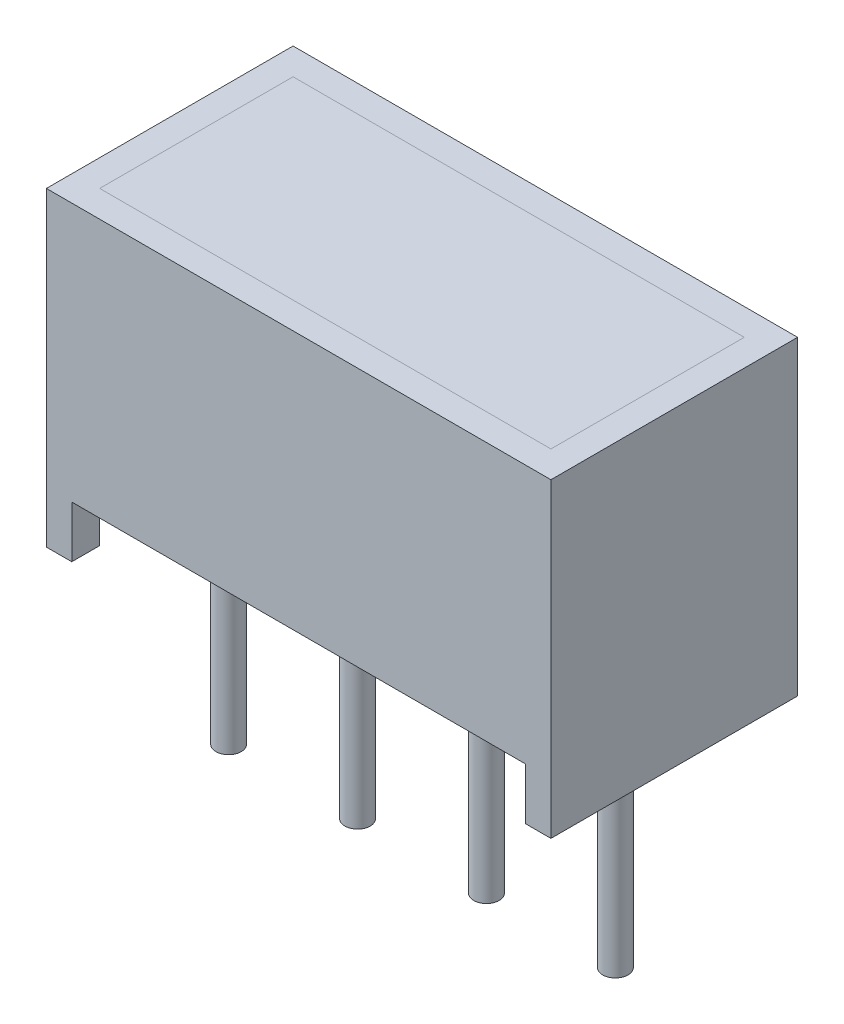
from build123d import *

# Parameters (mm, degrees)
SKETCH1_W          = 4.86
SKETCH1_H          = 6.12
EXTRUDE1_DEPTH     = 4.97
SKETCH3_W          = 8.94
SKETCH3_H          = 1.02
CUT_EXTRUDE1_DEPTH = 5.86
SKETCH2_W          = 8.89
SKETCH2_H          = 3.81
CUT_EXTRUDE2_DEPTH = 3.06
SKETCH4_R          = 0.25
EXTRUDE2_DEPTH     = 1.02
SKETCH4_3_R        = 0.25
EXTRUDE3_DEPTH     = 4
SKETCH2_3_W        = 8.89
SKETCH2_3_H        = 3.81
EXTRUDE4_DEPTH     = 3.06
SKETCH5_W          = 0.5
SKETCH5_H          = 1.02
CUT_EXTRUDE3_DEPTH = 0.5
SKETCH6_W          = 0.025316455
SKETCH6_H          = 0.026582278
SKETCH6_W_2        = 0.025316456
CUT_EXTRUDE4_DEPTH = 0.01


with BuildPart() as part:
    # Sketch1 → Extrude1 (new body, symmetric)
    with BuildSketch(Plane(origin=(0, 0, 0), x_dir=(0, 0, -1), z_dir=(1, 0, 0))):
        Rectangle(SKETCH1_W, SKETCH1_H)
    extrude(amount=EXTRUDE1_DEPTH, both=True)

    # Sketch3 → Cut-Extrude1 (cut, through all)
    with BuildSketch(Plane.XY.offset(2.43)):
        with Locations((0, -2.55)):
            Rectangle(SKETCH3_W, SKETCH3_H)
    extrude(amount=-CUT_EXTRUDE1_DEPTH, mode=Mode.SUBTRACT)

    # Sketch2 → Cut-Extrude2 (cut)
    with BuildSketch(Plane(origin=(0, 3.06, 0), x_dir=(-1, 0, 0), z_dir=(0, 1, 0))):
        Rectangle(SKETCH2_W, SKETCH2_H)
    extrude(amount=-CUT_EXTRUDE2_DEPTH, mode=Mode.SUBTRACT)

    # Sketch4 → Extrude2 (add)
    with BuildSketch(Plane.XZ.offset(3.06)):
        with Locations((-3.81, 0)):
            Circle(SKETCH4_R)
        with Locations((-1.27, 0)):
            Circle(SKETCH4_R)
        with Locations((1.27, 0)):
            Circle(SKETCH4_R)
        with Locations((3.81, 0)):
            Circle(SKETCH4_R)
    extrude(amount=-EXTRUDE2_DEPTH)

    # Sketch4_3 → Extrude3 (add)
    with BuildSketch(Plane.XZ.offset(3.06)):
        with Locations((-3.81, 0)):
            Circle(SKETCH4_3_R)
        with Locations((-1.27, 0)):
            Circle(SKETCH4_3_R)
        with Locations((1.27, 0)):
            Circle(SKETCH4_3_R)
        with Locations((3.81, 0)):
            Circle(SKETCH4_3_R)
    extrude(amount=EXTRUDE3_DEPTH)

    # Sketch5 → Cut-Extrude3 (cut)
    with BuildSketch(Plane.ZY.offset(4.97)):
        with Locations((1.63, -2.55)):
            Rectangle(SKETCH5_W, SKETCH5_H)
    extrude(amount=-CUT_EXTRUDE3_DEPTH, mode=Mode.SUBTRACT)

    # Sketch6 → Cut-Extrude4 (cut)
    with BuildSketch(Plane.XZ.offset(2.04)):
        Polygon((-0.559679779, -1.979541267), (-0.583137058, -2.054224811), (-0.607879937, -2.054224811), (-0.624296077, -2.003888577), (-0.639822184, -2.054224811), (-0.665553988, -2.054224811), (-0.688793703, -1.979541267), (-0.663615697, -1.979541267), (-0.650621235, -2.031024653), (-0.634205096, -1.979541267), (-0.612705887, -1.979541267), (-0.59638864, -2.031024653), (-0.583572184, -1.979541267), align=None)
        Polygon((-0.425502564, -1.979541267), (-0.448959842, -2.054224811), (-0.473702722, -2.054224811), (-0.490118861, -2.003888577), (-0.505644969, -2.054224811), (-0.531376773, -2.054224811), (-0.554616488, -1.979541267), (-0.529438482, -1.979541267), (-0.51644402, -2.031024653), (-0.50002788, -1.979541267), (-0.478528672, -1.979541267), (-0.462211425, -2.031024653), (-0.449394969, -1.979541267), align=None)
        Polygon((-0.291325349, -1.979541267), (-0.314782627, -2.054224811), (-0.339525507, -2.054224811), (-0.355941646, -2.003888577), (-0.371467754, -2.054224811), (-0.397199558, -2.054224811), (-0.420439273, -1.979541267), (-0.395261266, -1.979541267), (-0.382266804, -2.031024653), (-0.365850665, -1.979541267), (-0.344351456, -1.979541267), (-0.32803421, -2.031024653), (-0.315217754, -1.979541267), align=None)
        with Locations((-0.263477248, -2.040933672)):
            Rectangle(SKETCH6_W, SKETCH6_H)
        with BuildLine():
            add(Edge.make_bspline(
                [(-0.147021551, -2.023053925), (-0.14705804, -2.024276067), (-0.147129693, -2.026675945), (-0.14773941, -2.030183523), (-0.148732896, -2.033508228), (-0.150107014, -2.036670889), (-0.151895817, -2.039649507), (-0.154105407, -2.042429784), (-0.15666982, -2.045064584), (-0.15963603, -2.047470715), (-0.162916139, -2.049675091), (-0.166513715, -2.05157209), (-0.170392419, -2.053168573), (-0.174541005, -2.054507125), (-0.178987445, -2.055495705), (-0.183704974, -2.056219651), (-0.188698393, -2.05669298), (-0.192121971, -2.056734947), (-0.193876773, -2.056756457)],
                knots=[0, 0, 0, 0, 0.907352243, 1.781736951, 2.63548328, 3.47985091, 4.336556021, 5.208523475, 6.112432747, 7.062451073, 8.040435374, 9.043840564, 10.077958095, 11.152835584, 12.277940427, 13.457536469, 14.696825396, 16, 16, 16, 16], degree=3))
            add(Edge.make_bspline(
                [(-0.193876773, -2.056756457), (-0.195895028, -2.056732385), (-0.19980421, -2.056685761), (-0.205467735, -2.056257161), (-0.210735773, -2.055611022), (-0.215631488, -2.05464448), (-0.220236087, -2.053443715), (-0.224669354, -2.052152424), (-0.228950666, -2.050688008), (-0.231723756, -2.04958785), (-0.233097501, -2.049042849)],
                knots=[0, 0, 0, 0, 1.203215828, 2.33052265, 3.384689099, 4.366106119, 5.303329643, 6.221311756, 7.118865988, 8, 8, 8, 8], degree=3))
            Line((-0.233097501, -2.049042849), (-0.233097501, -2.025110887))
            Line((-0.233097501, -2.025110887), (-0.230249399, -2.025110887))
            add(Edge.make_bspline(
                [(-0.230249399, -2.025110887), (-0.228884085, -2.026192342), (-0.226161473, -2.028348903), (-0.22172824, -2.031111508), (-0.217080594, -2.033513671), (-0.212235123, -2.035487673), (-0.207338278, -2.037073997), (-0.202462901, -2.038167525), (-0.197697313, -2.038914874), (-0.194538744, -2.03899538), (-0.192986741, -2.039034938)],
                knots=[0, 0, 0, 0, 1.030622468, 2.055194264, 3.087043286, 4.125157485, 5.149848264, 6.130935704, 7.081611712, 8, 8, 8, 8], degree=3))
            add(Edge.make_bspline(
                [(-0.192986741, -2.039034938), (-0.192557965, -2.039034014), (-0.191639988, -2.039032037), (-0.190178462, -2.03890431), (-0.188526651, -2.038808733), (-0.186754142, -2.038601549), (-0.184957415, -2.038379688), (-0.183295014, -2.038004763), (-0.181785419, -2.037639896), (-0.180878898, -2.037271899), (-0.180447184, -2.037096647)],
                knots=[0, 0, 0, 0, 0.806402781, 1.726445712, 2.758724871, 3.919014682, 5.083870887, 6.16165551, 7.124521387, 8, 8, 8, 8], degree=3))
            add(Edge.make_bspline(
                [(-0.180447184, -2.037096647), (-0.179967621, -2.036868505), (-0.179025178, -2.036420158), (-0.177731579, -2.035609839), (-0.176563899, -2.034726374), (-0.175506527, -2.033761443), (-0.174632246, -2.032595693), (-0.174008379, -2.031187021), (-0.173663487, -2.029538003), (-0.173624463, -2.0283628), (-0.17360383, -2.027741425)],
                knots=[0, 0, 0, 0, 1.024747072, 2.013846092, 2.940605744, 3.850156746, 4.769278501, 5.73222711, 6.800942666, 8, 8, 8, 8], degree=3))
            add(Edge.make_bspline(
                [(-0.17360383, -2.027741425), (-0.173635674, -2.027195788), (-0.17369829, -2.026122904), (-0.174275483, -2.02458779), (-0.175184922, -2.023178621), (-0.176466512, -2.021909847), (-0.178059687, -2.020760313), (-0.180002071, -2.019778008), (-0.182252192, -2.01890482), (-0.183896263, -2.018486842), (-0.184758893, -2.018267533)],
                knots=[0, 0, 0, 0, 0.82557554, 1.623324704, 2.456147571, 3.35491006, 4.343819762, 5.427079081, 6.650009487, 8, 8, 8, 8], degree=3))
            add(Edge.make_bspline(
                [(-0.184758893, -2.018267533), (-0.186727519, -2.017819292), (-0.190766529, -2.016899642), (-0.196916354, -2.015760888), (-0.203044705, -2.014486028), (-0.206997471, -2.013279385), (-0.208928197, -2.012690001)],
                knots=[0, 0, 0, 0, 0.976100998, 2.002656142, 3.024398856, 4, 4, 4, 4], degree=3))
            add(Edge.make_bspline(
                [(-0.208928197, -2.012690001), (-0.209966715, -2.012337011), (-0.211988288, -2.011649883), (-0.214879799, -2.010488223), (-0.217541027, -2.009218394), (-0.21998074, -2.007862839), (-0.222181429, -2.006390299), (-0.224175697, -2.004848921), (-0.225938813, -2.003208881), (-0.227485618, -2.001469115), (-0.228810521, -1.999618412), (-0.229962906, -1.997673215), (-0.230945526, -1.995617795), (-0.231723564, -1.993447572), (-0.232348203, -1.991173917), (-0.232767185, -1.988796205), (-0.233066203, -1.986313076), (-0.233086926, -1.984618691), (-0.233097501, -1.983754084)],
                knots=[0, 0, 0, 0, 1.287047841, 2.5053592, 3.654260482, 4.74538952, 5.777514103, 6.75871007, 7.700244599, 8.599107454, 9.48590269, 10.366941872, 11.24940663, 12.154970331, 13.068988358, 14.012872203, 14.986013017, 16, 16, 16, 16], degree=3))
            add(Edge.make_bspline(
                [(-0.233097501, -1.983754084), (-0.233060199, -1.982597939), (-0.232986789, -1.980322667), (-0.232385361, -1.976993622), (-0.231358771, -1.973844886), (-0.229972707, -1.970841423), (-0.228144079, -1.968028337), (-0.225959285, -1.965349789), (-0.223335237, -1.962878198), (-0.220358116, -1.960577864), (-0.217070731, -1.958498465), (-0.213531748, -1.956667909), (-0.209762459, -1.955131258), (-0.205776912, -1.953857364), (-0.201558443, -1.952902693), (-0.19712121, -1.952183761), (-0.192447422, -1.951770579), (-0.189256, -1.951719329), (-0.187626773, -1.951693166)],
                knots=[0, 0, 0, 0, 0.894990994, 1.761326291, 2.609044902, 3.454222546, 4.315366365, 5.200560057, 6.125081389, 7.100429509, 8.110379559, 9.133447974, 10.182136699, 11.259192205, 12.370181258, 13.528580438, 14.738335141, 16, 16, 16, 16], degree=3))
            add(Edge.make_bspline(
                [(-0.187626773, -1.951693166), (-0.185958079, -1.951715319), (-0.18262352, -1.951759586), (-0.177642181, -1.952138144), (-0.172687752, -1.952690455), (-0.167825328, -1.953539696), (-0.163133165, -1.954507928), (-0.158714051, -1.955607201), (-0.154634498, -1.956844707), (-0.152060845, -1.957799109), (-0.15081902, -1.958259621)],
                knots=[0, 0, 0, 0, 1.065407564, 2.129008667, 3.188544425, 4.247469455, 5.279542408, 6.247502114, 7.154394069, 8, 8, 8, 8], degree=3))
            Line((-0.15081902, -1.958259621), (-0.15081902, -1.98080709))
            Line((-0.15081902, -1.98080709), (-0.153647342, -1.98080709))
            add(Edge.make_bspline(
                [(-0.153647342, -1.98080709), (-0.154720846, -1.980007802), (-0.156911624, -1.978376637), (-0.160561227, -1.976274901), (-0.164528847, -1.97433481), (-0.168810474, -1.972643153), (-0.173270255, -1.971185146), (-0.177853013, -1.970165587), (-0.182479229, -1.96952388), (-0.185580933, -1.969451091), (-0.187132311, -1.969414685)],
                knots=[0, 0, 0, 0, 0.892265782, 1.820912499, 2.804518821, 3.836954028, 4.889985052, 5.931488012, 6.965393252, 8, 8, 8, 8], degree=3))
            add(Edge.make_bspline(
                [(-0.187132311, -1.969414685), (-0.188227916, -1.969436587), (-0.190425559, -1.969480521), (-0.193694751, -1.969865407), (-0.196935229, -1.97050426), (-0.198969911, -1.971320311), (-0.199988323, -1.971728767)],
                knots=[0, 0, 0, 0, 0.999122297, 2.004111588, 3.001004448, 4, 4, 4, 4], degree=3))
            add(Edge.make_bspline(
                [(-0.199988323, -1.971728767), (-0.200422053, -1.971929946), (-0.201289223, -1.97233217), (-0.202496765, -1.973111795), (-0.203617737, -1.974028139), (-0.204613319, -1.975080896), (-0.205457753, -1.97624925), (-0.20607678, -1.977516832), (-0.206451272, -1.978880714), (-0.206493619, -1.979815813), (-0.206515222, -1.980292849)],
                knots=[0, 0, 0, 0, 1.004925302, 2.009180302, 3.014392739, 4.04465309, 5.049195417, 6.035570224, 6.99785458, 8, 8, 8, 8], degree=3))
            add(Edge.make_bspline(
                [(-0.206515222, -1.980292849), (-0.206480784, -1.980931015), (-0.206414976, -1.98215049), (-0.205808391, -1.983866286), (-0.204823558, -1.98534472), (-0.203662953, -1.98633964), (-0.202545824, -1.987037078), (-0.201510164, -1.987547589), (-0.200300937, -1.988030948), (-0.198929689, -1.988528416), (-0.197393362, -1.989019603), (-0.195684805, -1.98949515), (-0.193802088, -1.989944446), (-0.192486214, -1.990230637), (-0.191800032, -1.990379875)],
                knots=[0, 0, 0, 0, 1.173816843, 2.243057204, 3.312297565, 4.415174738, 5.03266065, 5.73970059, 6.541434878, 7.433956553, 8.430083051, 9.515931566, 10.70464786, 12, 12, 12, 12], degree=3))
            add(Edge.make_bspline(
                [(-0.191800032, -1.990379875), (-0.18996711, -1.990755319), (-0.186372144, -1.99149169), (-0.180972919, -1.992604056), (-0.175467931, -1.993869415), (-0.17179678, -1.995021411), (-0.169885475, -1.995621172)],
                knots=[0, 0, 0, 0, 0.995749986, 1.952994291, 2.934271555, 4, 4, 4, 4], degree=3))
            add(Edge.make_bspline(
                [(-0.169885475, -1.995621172), (-0.168938987, -1.995940531), (-0.167087503, -1.996565249), (-0.164445956, -1.997649933), (-0.161996903, -1.998832022), (-0.159718632, -2.000054508), (-0.157656551, -2.001417725), (-0.155763327, -2.002832372), (-0.154080308, -2.004360481), (-0.152582359, -2.005973339), (-0.151263958, -2.007683771), (-0.150128994, -2.009521874), (-0.149165848, -2.011476403), (-0.148357717, -2.013549474), (-0.1477797, -2.015756543), (-0.147345642, -2.018082843), (-0.14705482, -2.020528158), (-0.147032765, -2.022202605), (-0.147021551, -2.023053925)],
                knots=[0, 0, 0, 0, 1.237386967, 2.420528625, 3.534815053, 4.605870898, 5.620827102, 6.594482803, 7.531295079, 8.432978826, 9.318460435, 10.202471551, 11.10474705, 12.014900263, 12.954095338, 13.926516828, 14.945802342, 16, 16, 16, 16], degree=3))
        make_face()
        with BuildLine():
            Line((-0.054616488, -2.054224811), (-0.078667121, -2.054224811))
            Line((-0.078667121, -2.054224811), (-0.078667121, -2.046392533))
            add(Edge.make_bspline(
                [(-0.078667121, -2.046392533), (-0.079760376, -2.0472012), (-0.081868156, -2.048760299), (-0.085041896, -2.050839063), (-0.088070617, -2.052622225), (-0.090992218, -2.054164378), (-0.094007573, -2.055355225), (-0.097235076, -2.056177081), (-0.10073734, -2.056678201), (-0.103164314, -2.056729792), (-0.104418703, -2.056756457)],
                knots=[0, 0, 0, 0, 1.150906677, 2.218931226, 3.20955724, 4.125565256, 5.012676028, 5.946647191, 6.938718366, 8, 8, 8, 8], degree=3))
            add(Edge.make_bspline(
                [(-0.104418703, -2.056756457), (-0.105435048, -2.056733728), (-0.107414166, -2.056689468), (-0.110291496, -2.05634473), (-0.112998808, -2.055806584), (-0.115514957, -2.055000728), (-0.117880303, -2.054026611), (-0.120031821, -2.052767524), (-0.12201951, -2.051308187), (-0.123822888, -2.049631251), (-0.125413507, -2.047710289), (-0.126800558, -2.045587538), (-0.12797637, -2.0432529), (-0.128918008, -2.040701533), (-0.129672941, -2.037943089), (-0.130196919, -2.034963882), (-0.130517498, -2.031776743), (-0.130549439, -2.029581614), (-0.130565855, -2.028453451)],
                knots=[0, 0, 0, 0, 1.108935798, 2.159418225, 3.158520219, 4.116592843, 5.038730546, 5.944611115, 6.829677354, 7.725673622, 8.624842385, 9.544872214, 10.487719724, 11.471363217, 12.50822837, 13.604887271, 14.769056852, 16, 16, 16, 16], degree=3))
            Line((-0.130565855, -2.028453451), (-0.130565855, -1.979541267))
            Line((-0.130565855, -1.979541267), (-0.106515222, -1.979541267))
            Line((-0.106515222, -1.979541267), (-0.106515222, -2.017120381))
            add(Edge.make_bspline(
                [(-0.106515222, -2.017120381), (-0.106513587, -2.018036852), (-0.106510456, -2.019791068), (-0.106428117, -2.022296874), (-0.106307217, -2.024565047), (-0.106168512, -2.026607075), (-0.105915495, -2.028453826), (-0.105537787, -2.030119987), (-0.105066961, -2.031639589), (-0.104602642, -2.032546291), (-0.104379146, -2.032982723)],
                knots=[0, 0, 0, 0, 1.361401701, 2.605856924, 3.723918663, 4.735739235, 5.645738665, 6.489217889, 7.27279937, 8, 8, 8, 8], degree=3))
            add(Edge.make_bspline(
                [(-0.104379146, -2.032982723), (-0.104149106, -2.033381371), (-0.103696868, -2.034165078), (-0.102777057, -2.035172226), (-0.101701074, -2.036009132), (-0.100431435, -2.036681776), (-0.098938354, -2.037165479), (-0.097206354, -2.037512227), (-0.095220338, -2.03772605), (-0.093811419, -2.037754212), (-0.093065855, -2.037769115)],
                knots=[0, 0, 0, 0, 0.849057291, 1.669173542, 2.503217716, 3.359509317, 4.311793648, 5.394940091, 6.621469141, 8, 8, 8, 8], degree=3))
            add(Edge.make_bspline(
                [(-0.093065855, -2.037769115), (-0.09252459, -2.037751658), (-0.091411713, -2.037715764), (-0.089706501, -2.037485836), (-0.087917472, -2.037124179), (-0.085403275, -2.036465156), (-0.08222713, -2.035285978), (-0.079862991, -2.033927176), (-0.078667121, -2.033239843)],
                knots=[0, 0, 0, 0, 0.638164724, 1.312110757, 2.025558264, 2.789159289, 4.375836335, 6, 6, 6, 6], degree=3))
            Line((-0.078667121, -2.033239843), (-0.078667121, -1.979541267))
            Line((-0.078667121, -1.979541267), (-0.054616488, -1.979541267))
            Line((-0.054616488, -1.979541267), (-0.054616488, -2.054224811))
        make_face()
        with BuildLine():
            Line((0.042851866, -2.054224811), (0.018801234, -2.054224811))
            Line((0.018801234, -2.054224811), (0.018801234, -2.016645697))
            add(Edge.make_bspline(
                [(0.018801234, -2.016645697), (0.018780909, -2.015115224), (0.018740374, -2.012062812), (0.018406794, -2.008306036), (0.018073085, -2.005458246), (0.017696262, -2.003622179), (0.017266076, -2.002073843), (0.01685363, -2.001188105), (0.016665158, -2.000783356)],
                knots=[0, 0, 0, 0, 1.709235885, 3.408940626, 4.211008593, 4.910095588, 5.501954032, 6, 6, 6, 6], degree=3))
            add(Edge.make_bspline(
                [(0.016665158, -2.000783356), (0.016420729, -2.000385233), (0.015941493, -1.999604658), (0.015003677, -1.998592636), (0.013907028, -1.997756422), (0.012628305, -1.997091473), (0.011143651, -1.996605574), (0.009430977, -1.996218915), (0.007445007, -1.996050355), (0.006037638, -1.996015446), (0.005292531, -1.995996963)],
                knots=[0, 0, 0, 0, 0.860145871, 1.686437142, 2.528070002, 3.393017362, 4.331453407, 5.402595683, 6.624848233, 8, 8, 8, 8], degree=3))
            add(Edge.make_bspline(
                [(0.005292531, -1.995996963), (0.004160641, -1.996053544), (0.001849408, -1.996169077), (-0.001011883, -1.996882668), (-0.003338759, -1.997694965), (-0.005184379, -1.998469202), (-0.007100908, -1.999423828), (-0.008384333, -2.000150902), (-0.009046868, -2.000526235)],
                knots=[0, 0, 0, 0, 1.338419466, 2.732951426, 3.468143565, 4.254837763, 5.099104234, 6, 6, 6, 6], degree=3))
            Line((-0.009046868, -2.000526235), (-0.009046868, -2.054224811))
            Line((-0.009046868, -2.054224811), (-0.033097501, -2.054224811))
            Line((-0.033097501, -2.054224811), (-0.033097501, -1.979541267))
            Line((-0.033097501, -1.979541267), (-0.009046868, -1.979541267))
            Line((-0.009046868, -1.979541267), (-0.009046868, -1.987373546))
            add(Edge.make_bspline(
                [(-0.009046868, -1.987373546), (-0.00798963, -1.986567108), (-0.005931655, -1.984997329), (-0.002754902, -1.982963919), (0.000315809, -1.981154063), (0.003370331, -1.979641928), (0.006494829, -1.978443328), (0.00976246, -1.977627725), (0.013179172, -1.977084777), (0.015515845, -1.977034965), (0.016704715, -1.977009621)],
                knots=[0, 0, 0, 0, 1.126064518, 2.191951536, 3.19307265, 4.144813015, 5.076393104, 6.021983703, 6.993610568, 8, 8, 8, 8], degree=3))
            add(Edge.make_bspline(
                [(0.016704715, -1.977009621), (0.017700986, -1.977035011), (0.019645885, -1.977084574), (0.022480646, -1.977394284), (0.025152066, -1.977944948), (0.027644341, -1.978742778), (0.029986958, -1.979728391), (0.032148914, -1.980959901), (0.03414094, -1.982418341), (0.035969509, -1.984079282), (0.03759969, -1.98596924), (0.039019176, -1.988085613), (0.0401906, -1.990434342), (0.041199432, -1.992981478), (0.041933657, -1.995759249), (0.042460108, -1.998750015), (0.042810538, -2.001955197), (0.042837815, -2.004171097), (0.042851866, -2.005312628)],
                knots=[0, 0, 0, 0, 1.088441561, 2.124831547, 3.110816719, 4.062969431, 4.979391633, 5.88258537, 6.774334107, 7.671621258, 8.575503974, 9.49441354, 10.447872957, 11.437639084, 12.482478955, 13.580222388, 14.753440527, 16, 16, 16, 16], degree=3))
            Line((0.042851866, -2.005312628), (0.042851866, -2.054224811))
        make_face()
        Polygon((0.137788575, -2.054224811), (0.065636677, -2.054224811), (0.065636677, -1.954224811), (0.090953132, -1.954224811), (0.090953132, -2.03523747), (0.137788575, -2.03523747), align=None)
        Polygon((0.225130347, -2.054224811), (0.152978449, -2.054224811), (0.152978449, -1.954224811), (0.225130347, -1.954224811), (0.225130347, -1.973212153), (0.178294904, -1.973212153), (0.178294904, -1.990933672), (0.221332879, -1.990933672), (0.221332879, -2.009921014), (0.178294904, -2.009921014), (0.178294904, -2.03523747), (0.225130347, -2.03523747), align=None)
        with BuildLine():
            add(Edge.make_bspline(
                [(0.341586044, -2.004323704), (0.341566728, -2.005471393), (0.341528476, -2.007744279), (0.341233285, -2.011109085), (0.340707259, -2.014374761), (0.340028078, -2.017559009), (0.339105572, -2.020637937), (0.338023859, -2.023645514), (0.336714213, -2.026551008), (0.33520936, -2.029352442), (0.333559888, -2.032024545), (0.331785139, -2.034544754), (0.32993936, -2.036927972), (0.327950047, -2.039122866), (0.325870865, -2.041164885), (0.323695337, -2.043055699), (0.321390272, -2.04475913), (0.31978311, -2.045782014), (0.31897924, -2.04629364)],
                knots=[0, 0, 0, 0, 1.105570398, 2.18947457, 3.250358341, 4.290584537, 5.323553275, 6.344225964, 7.367641686, 8.3905646, 9.405808457, 10.390761353, 11.358902336, 12.307789878, 13.241960776, 14.165076779, 15.082208636, 16, 16, 16, 16], degree=3))
            add(Edge.make_bspline(
                [(0.31897924, -2.04629364), (0.317740019, -2.04700581), (0.315255254, -2.048433784), (0.311271308, -2.050101915), (0.307140189, -2.051509871), (0.302781635, -2.052558061), (0.298135286, -2.053286794), (0.293140629, -2.053849844), (0.287739502, -2.054150209), (0.284004619, -2.054199377), (0.282072594, -2.054224811)],
                knots=[0, 0, 0, 0, 0.896298978, 1.797171328, 2.70531317, 3.633678302, 4.606491125, 5.655688921, 6.787306437, 8, 8, 8, 8], degree=3))
            Line((0.282072594, -2.054224811), (0.246649335, -2.054224811))
            Line((0.246649335, -2.054224811), (0.246649335, -1.954224811))
            Line((0.246649335, -1.954224811), (0.283081297, -1.954224811))
            add(Edge.make_bspline(
                [(0.283081297, -1.954224811), (0.285060021, -1.954241507), (0.288876734, -1.95427371), (0.294387152, -1.954689678), (0.299485531, -1.955289198), (0.30417011, -1.95621589), (0.308478516, -1.957324541), (0.312409539, -1.958687577), (0.316021428, -1.960185849), (0.318200255, -1.961459596), (0.319256139, -1.962076868)],
                knots=[0, 0, 0, 0, 1.267192274, 2.444256634, 3.537982003, 4.553396635, 5.500903572, 6.385021601, 7.217363933, 8, 8, 8, 8], degree=3))
            add(Edge.make_bspline(
                [(0.319256139, -1.962076868), (0.320107092, -1.962613409), (0.321799217, -1.963680322), (0.324200431, -1.965462175), (0.326429858, -1.967418252), (0.328558362, -1.96947007), (0.330538176, -1.971672958), (0.332381389, -1.974011662), (0.334085156, -1.976489769), (0.335643311, -1.979099188), (0.337063396, -1.981829428), (0.338255476, -1.984701773), (0.339294838, -1.987684647), (0.34014092, -1.990783586), (0.34079725, -1.994000976), (0.341243334, -1.997338456), (0.341526767, -2.000791645), (0.341566118, -2.003136438), (0.341586044, -2.004323704)],
                knots=[0, 0, 0, 0, 0.964043478, 1.917004671, 2.862223898, 3.805158963, 4.749279098, 5.698713747, 6.657523689, 7.629652222, 8.610369353, 9.604453025, 10.607693792, 11.636365947, 12.681120053, 13.752669011, 14.862083412, 16, 16, 16, 16], degree=3))
        make_face()
        with BuildLine():
            add(Edge.make_bspline(
                [(0.315003765, -2.004165476), (0.314993294, -2.003360763), (0.314972755, -2.001782271), (0.314784432, -1.999466095), (0.314513845, -1.997240046), (0.314124711, -1.995096413), (0.313584278, -1.993046265), (0.312952097, -1.991084696), (0.312225007, -1.989205772), (0.311344077, -1.987428113), (0.310370252, -1.985719776), (0.309222809, -1.984134248), (0.307974458, -1.982621365), (0.306596175, -1.98119338), (0.305053233, -1.979887484), (0.303393131, -1.978657408), (0.301592773, -1.977529082), (0.300319785, -1.976869032), (0.299675442, -1.976534938)],
                knots=[0, 0, 0, 0, 1.152052275, 2.259818351, 3.325348653, 4.362224493, 5.376551665, 6.358740615, 7.312387502, 8.258104984, 9.197203025, 10.124507262, 11.056413058, 12.004389423, 12.961766972, 13.947352551, 14.961020569, 16, 16, 16, 16], degree=3))
            add(Edge.make_bspline(
                [(0.299675442, -1.976534938), (0.299000545, -1.976228226), (0.297662851, -1.975620301), (0.295592028, -1.974889109), (0.293502644, -1.974316273), (0.291301045, -1.973885415), (0.288831285, -1.973563484), (0.285905703, -1.973366226), (0.282449794, -1.973224056), (0.279963079, -1.973216305), (0.278631139, -1.973212153)],
                knots=[0, 0, 0, 0, 0.826967603, 1.639107464, 2.447640171, 3.242670507, 4.14065217, 5.225198036, 6.513753944, 8, 8, 8, 8], degree=3))
            Line((0.278631139, -1.973212153), (0.27196579, -1.973212153))
            Line((0.27196579, -1.973212153), (0.27196579, -2.03523747))
            Line((0.27196579, -2.03523747), (0.278631139, -2.03523747))
            add(Edge.make_bspline(
                [(0.278631139, -2.03523747), (0.279389346, -2.035232724), (0.280853112, -2.035223562), (0.28296935, -2.035180448), (0.284935166, -2.035133734), (0.286739971, -2.035016697), (0.288392315, -2.034946197), (0.289878462, -2.034762526), (0.291215412, -2.034628051), (0.292787893, -2.034350329), (0.294643079, -2.033944353), (0.296809869, -2.033261196), (0.298950568, -2.032411621), (0.300339118, -2.031726542), (0.301040158, -2.031380666)],
                knots=[0, 0, 0, 0, 1.186805873, 2.291202465, 3.313317863, 4.264127762, 5.122212376, 5.900577546, 6.607154111, 7.224697658, 8.398873738, 9.57716935, 10.776782771, 12, 12, 12, 12], degree=3))
            add(Edge.make_bspline(
                [(0.301040158, -2.031380666), (0.301625271, -2.031039148), (0.302779192, -2.03036563), (0.304402732, -2.02923158), (0.305910321, -2.02802377), (0.307306799, -2.026735629), (0.308568385, -2.025346244), (0.309724473, -2.023886778), (0.31072986, -2.022326457), (0.311969113, -2.02013763), (0.313216203, -2.017112873), (0.314248603, -2.013140119), (0.31488775, -2.008781207), (0.314964103, -2.005743467), (0.315003765, -2.004165476)],
                knots=[0, 0, 0, 0, 0.755237594, 1.489427721, 2.205882609, 2.908165467, 3.605466573, 4.296695275, 4.981837198, 5.673065901, 7.099889822, 8.61390339, 10.241051878, 12, 12, 12, 12], degree=3))
        make_face(mode=Mode.SUBTRACT)
        with Locations((0.373231613, -2.040933672)):
            Rectangle(SKETCH6_W_2, SKETCH6_H)
        with BuildLine():
            add(Edge.make_bspline(
                [(0.447875601, -2.056756457), (0.446285484, -2.056734654), (0.44316434, -2.056691857), (0.438593052, -2.056214829), (0.434227686, -2.055497533), (0.430082063, -2.054475214), (0.42617152, -2.053134695), (0.42251657, -2.051464688), (0.419099898, -2.049497493), (0.417037978, -2.047912596), (0.416012468, -2.047124337)],
                knots=[0, 0, 0, 0, 1.123701398, 2.205645569, 3.245398653, 4.249180969, 5.220497262, 6.163202923, 7.086456062, 8, 8, 8, 8], degree=3))
            add(Edge.make_bspline(
                [(0.416012468, -2.047124337), (0.415060833, -2.046269504), (0.413161243, -2.044563143), (0.410693616, -2.0415926), (0.40857554, -2.038303627), (0.406763285, -2.034711974), (0.405331333, -2.030792089), (0.404338798, -2.026542194), (0.403711194, -2.021984865), (0.403645243, -2.01883666), (0.40361136, -2.017219273)],
                knots=[0, 0, 0, 0, 0.916342154, 1.829140869, 2.758848968, 3.716597128, 4.708179637, 5.743612459, 6.840783343, 8, 8, 8, 8], degree=3))
            add(Edge.make_bspline(
                [(0.40361136, -2.017219273), (0.403650121, -2.015516046), (0.403725243, -2.012214966), (0.404389003, -2.007442779), (0.405458615, -2.003025098), (0.406996173, -1.99897319), (0.408926615, -1.995279998), (0.411191108, -1.991908164), (0.413811634, -1.988865239), (0.415818772, -1.9871198), (0.416823385, -1.986246172)],
                knots=[0, 0, 0, 0, 1.171797512, 2.271099083, 3.308930235, 4.294129479, 5.24602549, 6.17106565, 7.084581485, 8, 8, 8, 8], degree=3))
            add(Edge.make_bspline(
                [(0.416823385, -1.986246172), (0.41784917, -1.985477393), (0.419913127, -1.98393055), (0.423312667, -1.982035738), (0.42692488, -1.980431221), (0.430755996, -1.979185335), (0.434736515, -1.978236798), (0.438802055, -1.977509826), (0.442948422, -1.977089801), (0.445738608, -1.977036477), (0.447143797, -1.977009621)],
                knots=[0, 0, 0, 0, 0.952097844, 1.915695341, 2.885641886, 3.886921822, 4.905719434, 5.925883802, 6.95543633, 8, 8, 8, 8], degree=3))
            add(Edge.make_bspline(
                [(0.447143797, -1.977009621), (0.448390523, -1.977026585), (0.450842011, -1.977059941), (0.454442944, -1.977382599), (0.457891529, -1.977912763), (0.461188841, -1.978656357), (0.464361989, -1.979549156), (0.467421461, -1.980580437), (0.470386277, -1.981718378), (0.472286955, -1.982602593), (0.473231613, -1.983042058)],
                knots=[0, 0, 0, 0, 1.107671842, 2.178058178, 3.209662749, 4.206063564, 5.179815947, 6.137646632, 7.07438927, 8, 8, 8, 8], degree=3))
            Line((0.473231613, -1.983042058), (0.473231613, -2.0035919))
            Line((0.473231613, -2.0035919), (0.46988905, -2.0035919))
            add(Edge.make_bspline(
                [(0.46988905, -2.0035919), (0.469390281, -2.003173673), (0.468308346, -2.002266449), (0.466506994, -2.000865436), (0.464373483, -1.999314871), (0.462722275, -1.998428868), (0.461839208, -1.997955033)],
                knots=[0, 0, 0, 0, 0.792878214, 1.719922066, 2.780612869, 4, 4, 4, 4], degree=3))
            add(Edge.make_bspline(
                [(0.461839208, -1.997955033), (0.460911549, -1.997512164), (0.45900452, -1.996601741), (0.456444543, -1.995782198), (0.454255512, -1.995203661), (0.452443628, -1.994950851), (0.450510208, -1.994760503), (0.449174938, -1.994741108), (0.448488734, -1.99473114)],
                knots=[0, 0, 0, 0, 1.33256682, 2.739414054, 3.480190821, 4.267897792, 5.109861573, 6, 6, 6, 6], degree=3))
            add(Edge.make_bspline(
                [(0.448488734, -1.99473114), (0.447723185, -1.9947507), (0.446239587, -1.994788605), (0.444077985, -1.995065527), (0.442059909, -1.995544262), (0.440155501, -1.996182674), (0.438416754, -1.997078913), (0.436774224, -1.998091181), (0.435299749, -1.999345689), (0.433957802, -2.000763429), (0.432770318, -2.002353943), (0.431743565, -2.00408043), (0.430860839, -2.005938323), (0.430158946, -2.007936231), (0.429601436, -2.010066093), (0.42921187, -2.012328903), (0.428970092, -2.014728501), (0.428942149, -2.016374797), (0.428927816, -2.017219273)],
                knots=[0, 0, 0, 0, 1.087094245, 2.106738054, 3.087824582, 4.029427112, 4.95060567, 5.859714611, 6.763601524, 7.690850518, 8.627131371, 9.576106403, 10.539384251, 11.543302637, 12.578856349, 13.662518017, 14.800975475, 16, 16, 16, 16], degree=3))
            add(Edge.make_bspline(
                [(0.428927816, -2.017219273), (0.42894259, -2.01808343), (0.428971296, -2.019762442), (0.429204811, -2.022204053), (0.429620702, -2.024485485), (0.43019195, -2.026610804), (0.430916298, -2.028576823), (0.431821415, -2.030374219), (0.432857771, -2.032031027), (0.434102329, -2.033493639), (0.435466213, -2.03480996), (0.436981105, -2.035946095), (0.438640344, -2.036894239), (0.440422524, -2.037698703), (0.442355565, -2.038277101), (0.444412102, -2.038713793), (0.446601657, -2.039002349), (0.448112011, -2.039023912), (0.448884303, -2.039034938)],
                knots=[0, 0, 0, 0, 1.230336593, 2.390482092, 3.487897344, 4.52859895, 5.520747884, 6.465347575, 7.38981449, 8.296085817, 9.192433006, 10.084246191, 10.984321635, 11.908883871, 12.862027947, 13.850751296, 14.901019963, 16, 16, 16, 16], degree=3))
            add(Edge.make_bspline(
                [(0.448884303, -2.039034938), (0.449610146, -2.039026715), (0.451025148, -2.039010683), (0.45308357, -2.038794617), (0.455037487, -2.03851529), (0.456872034, -2.038074014), (0.458576283, -2.03753913), (0.460141936, -2.036968303), (0.461554543, -2.036364023), (0.462415878, -2.035896408), (0.462828132, -2.035672596)],
                knots=[0, 0, 0, 0, 1.200879421, 2.341068892, 3.423000803, 4.465923194, 5.460027553, 6.378409259, 7.223869634, 8, 8, 8, 8], degree=3))
            add(Edge.make_bspline(
                [(0.462828132, -2.035672596), (0.463536488, -2.03524491), (0.464897862, -2.034422951), (0.46672298, -2.033002491), (0.468367105, -2.031596051), (0.469391211, -2.030639284), (0.46988905, -2.030174178)],
                knots=[0, 0, 0, 0, 1.105932972, 2.12546697, 3.088749538, 4, 4, 4, 4], degree=3))
            Line((0.46988905, -2.030174178), (0.473231613, -2.030174178))
            Line((0.473231613, -2.030174178), (0.473231613, -2.050882248))
            add(Edge.make_bspline(
                [(0.473231613, -2.050882248), (0.472286237, -2.05131979), (0.470395256, -2.05219498), (0.467480478, -2.05334813), (0.464487236, -2.05432101), (0.461436006, -2.055213356), (0.458266374, -2.055911551), (0.454949025, -2.056400781), (0.45146772, -2.05670252), (0.449089304, -2.056738233), (0.447875601, -2.056756457)],
                knots=[0, 0, 0, 0, 0.952024047, 1.90427691, 2.862762905, 3.827874523, 4.80891974, 5.826446878, 6.890837857, 8, 8, 8, 8], degree=3))
        make_face()
        with BuildLine():
            add(Edge.make_bspline(
                [(0.565636677, -2.016922596), (0.565611757, -2.018427428), (0.565563181, -2.021360749), (0.565026973, -2.025633569), (0.564203511, -2.029664011), (0.563070186, -2.033464848), (0.561552333, -2.037007894), (0.559709918, -2.040303848), (0.557536328, -2.043356031), (0.555046009, -2.046146257), (0.552244523, -2.048644449), (0.549170758, -2.050840642), (0.545800891, -2.05264769), (0.542192145, -2.05417424), (0.538302838, -2.055330341), (0.534143744, -2.056148291), (0.529726234, -2.056682623), (0.526687869, -2.056731435), (0.525130347, -2.056756457)],
                knots=[0, 0, 0, 0, 1.120122129, 2.18341868, 3.201215738, 4.181270334, 5.131540819, 6.065757527, 6.988093576, 7.916512302, 8.844931028, 9.778115023, 10.722851943, 11.686686084, 12.691660064, 13.738321946, 14.84062285, 16, 16, 16, 16], degree=3))
            add(Edge.make_bspline(
                [(0.525130347, -2.056756457), (0.523572799, -2.056731517), (0.520534381, -2.056682865), (0.516117247, -2.056147395), (0.511963027, -2.055334678), (0.508078375, -2.054165443), (0.504464064, -2.052653352), (0.501090237, -2.050839911), (0.498016055, -2.048644658), (0.495214853, -2.046146147), (0.492723816, -2.043356262), (0.490552811, -2.040303032), (0.488701872, -2.03701324), (0.48722148, -2.033455965), (0.486048948, -2.029668757), (0.485236169, -2.025632759), (0.484696852, -2.021360968), (0.484648714, -2.018427502), (0.484624018, -2.016922596)],
                knots=[0, 0, 0, 0, 1.159424321, 2.261770074, 3.308474541, 4.308788811, 5.277191138, 6.221966496, 7.15518846, 8.08364496, 9.01210146, 9.934475036, 10.868729753, 11.817121636, 12.798654016, 13.816492484, 14.879832297, 16, 16, 16, 16], degree=3))
            add(Edge.make_bspline(
                [(0.484624018, -2.016922596), (0.484649141, -2.015411172), (0.484698226, -2.012458162), (0.485233596, -2.008159289), (0.486051613, -2.004098639), (0.487211646, -2.000290326), (0.488727919, -1.996738726), (0.490568943, -1.993436621), (0.492765411, -1.990390046), (0.49527491, -1.987600294), (0.498086704, -1.985103913), (0.501180635, -1.982931008), (0.504532555, -1.981094351), (0.508139754, -1.979572517), (0.512026309, -1.978437952), (0.516163252, -1.977620373), (0.520560646, -1.977082301), (0.523579384, -1.977034289), (0.525130347, -1.977009621)],
                knots=[0, 0, 0, 0, 1.124034801, 2.196132384, 3.217834281, 4.203147447, 5.152578239, 6.085969439, 7.010345409, 7.941219594, 8.872481455, 9.802010446, 10.748267785, 11.711250247, 12.709230373, 13.754967386, 14.846549946, 16, 16, 16, 16], degree=3))
            add(Edge.make_bspline(
                [(0.525130347, -1.977009621), (0.526701091, -1.977034334), (0.529759267, -1.977082447), (0.534202596, -1.977618786), (0.538376726, -1.978431312), (0.542274335, -1.979599382), (0.545898343, -1.981102652), (0.54924552, -1.982957598), (0.552330478, -1.985131948), (0.555098741, -1.987661777), (0.5575825, -1.990456731), (0.559744856, -1.993514411), (0.561580332, -1.996821987), (0.563056075, -2.000383862), (0.564230277, -2.004176494), (0.565050689, -2.008210921), (0.565556841, -2.012485827), (0.565609602, -2.01541797), (0.565636677, -2.016922596)],
                knots=[0, 0, 0, 0, 1.167473013, 2.273023816, 3.322954552, 4.326451713, 5.293391623, 6.234801871, 7.166614545, 8.093305908, 9.017100806, 9.942078766, 10.872536262, 11.824015763, 12.804065898, 13.820367293, 14.881523901, 16, 16, 16, 16], degree=3))
        make_face()
        with BuildLine():
            add(Edge.make_bspline(
                [(0.535929398, -2.035415476), (0.536284144, -2.034915283), (0.537006094, -2.033897331), (0.537882034, -2.032202139), (0.538641687, -2.030370871), (0.539260374, -2.028344588), (0.539770516, -2.026046811), (0.540072136, -2.023389879), (0.54030495, -2.020354993), (0.540314931, -2.018202185), (0.540320221, -2.017061046)],
                knots=[0, 0, 0, 0, 0.765094823, 1.557058493, 2.376706509, 3.238810155, 4.199844458, 5.312104478, 6.575226644, 8, 8, 8, 8], degree=3))
            add(Edge.make_bspline(
                [(0.540320221, -2.017061046), (0.540302532, -2.015986164), (0.540268642, -2.013926808), (0.540082272, -2.010967045), (0.539733597, -2.008283618), (0.539235719, -2.005866222), (0.538625949, -2.003695534), (0.537900014, -2.001753172), (0.537061496, -2.00003457), (0.536376029, -1.999029338), (0.536048069, -1.998548387)],
                knots=[0, 0, 0, 0, 1.337076348, 2.561692668, 3.686680134, 4.69989255, 5.629188848, 6.488203485, 7.276684665, 8, 8, 8, 8], degree=3))
            add(Edge.make_bspline(
                [(0.536048069, -1.998548387), (0.535709496, -1.99811055), (0.535048246, -1.997255433), (0.533890492, -1.996151799), (0.53261001, -1.995273849), (0.531229164, -1.994605184), (0.529788455, -1.994091675), (0.528282332, -1.993735634), (0.526725772, -1.993514471), (0.525665093, -1.993481793), (0.525130347, -1.993465318)],
                knots=[0, 0, 0, 0, 1.058499091, 2.067300666, 3.047512573, 4.018335651, 4.996351322, 5.969796037, 6.97646375, 8, 8, 8, 8], degree=3))
            add(Edge.make_bspline(
                [(0.525130347, -1.993465318), (0.524602445, -1.993476348), (0.523569886, -1.993497922), (0.522066808, -1.993676439), (0.520651155, -1.993976437), (0.51930599, -1.994380623), (0.518020842, -1.994991999), (0.516789565, -1.995840817), (0.515574178, -1.996917396), (0.51483585, -1.997767732), (0.514449968, -1.998212153)],
                knots=[0, 0, 0, 0, 1.04189444, 2.037910168, 2.982338511, 3.896140384, 4.804271323, 5.778885192, 6.839150358, 8, 8, 8, 8], degree=3))
            add(Edge.make_bspline(
                [(0.514449968, -1.998212153), (0.514114534, -1.998685821), (0.513410544, -1.999679929), (0.512561355, -2.001400298), (0.511792056, -2.003345789), (0.511112767, -2.005536925), (0.510581582, -2.008004465), (0.510223394, -2.010763078), (0.509978714, -2.013813013), (0.509953598, -2.015946319), (0.509940474, -2.017061046)],
                knots=[0, 0, 0, 0, 0.70629823, 1.482341141, 2.329662943, 3.254583898, 4.274063958, 5.401087491, 6.641978366, 8, 8, 8, 8], degree=3))
            add(Edge.make_bspline(
                [(0.509940474, -2.017061046), (0.509946414, -2.018063784), (0.50995792, -2.020005916), (0.510200115, -2.022808248), (0.510486942, -2.025416692), (0.510973512, -2.027804745), (0.51154535, -2.029989922), (0.512293393, -2.031941515), (0.513116733, -2.033696588), (0.513817088, -2.034724328), (0.51415329, -2.035217691)],
                knots=[0, 0, 0, 0, 1.270983191, 2.461674417, 3.564986371, 4.596265355, 5.549463796, 6.425202083, 7.244022889, 8, 8, 8, 8], degree=3))
            add(Edge.make_bspline(
                [(0.51415329, -2.035217691), (0.514493653, -2.035634466), (0.515164699, -2.036456164), (0.516312494, -2.037532304), (0.517580467, -2.038406862), (0.518930085, -2.039129851), (0.520396677, -2.039664234), (0.521956962, -2.040034167), (0.523614412, -2.040253307), (0.524747298, -2.040284677), (0.525328132, -2.040300761)],
                knots=[0, 0, 0, 0, 1.010886179, 1.993025998, 2.945391046, 3.898964935, 4.863589088, 5.87059323, 6.908247091, 8, 8, 8, 8], degree=3))
            add(Edge.make_bspline(
                [(0.525328132, -2.040300761), (0.52633576, -2.040248239), (0.528333567, -2.040144106), (0.530748989, -2.039427699), (0.532550647, -2.038572721), (0.533805445, -2.037713312), (0.534943754, -2.036652544), (0.535596619, -2.035833142), (0.535929398, -2.035415476)],
                knots=[0, 0, 0, 0, 1.49343762, 2.961012893, 3.700518105, 4.446788108, 5.208294864, 6, 6, 6, 6], degree=3))
        make_face(mode=Mode.SUBTRACT)
        with BuildLine():
            Line((0.656775917, -2.000526235), (0.656775917, -2.054224811))
            Line((0.656775917, -2.054224811), (0.632725284, -2.054224811))
            Line((0.632725284, -2.054224811), (0.632725284, -2.016368799))
            add(Edge.make_bspline(
                [(0.632725284, -2.016368799), (0.632719018, -2.015478799), (0.632706995, -2.013771234), (0.632684482, -2.011310904), (0.632569111, -2.009063562), (0.632472558, -2.007016227), (0.632273875, -2.005159841), (0.631996203, -2.003480133), (0.631567348, -2.001977136), (0.631159922, -2.001076022), (0.630964999, -2.000644906)],
                knots=[0, 0, 0, 0, 1.33997484, 2.570892857, 3.703483919, 4.727540125, 5.655929516, 6.512630168, 7.288405602, 8, 8, 8, 8], degree=3))
            add(Edge.make_bspline(
                [(0.630964999, -2.000644906), (0.630755074, -2.000259539), (0.630338949, -1.999495646), (0.629470904, -1.998527785), (0.628462595, -1.99771714), (0.627282434, -1.997075686), (0.62590375, -1.996577523), (0.624288629, -1.996228178), (0.622424772, -1.996047776), (0.621102484, -1.996014538), (0.62040329, -1.995996963)],
                knots=[0, 0, 0, 0, 0.859345536, 1.703436662, 2.532498256, 3.390183975, 4.328249457, 5.402602062, 6.626559876, 8, 8, 8, 8], degree=3))
            add(Edge.make_bspline(
                [(0.62040329, -1.995996963), (0.619815952, -1.996020359), (0.618635976, -1.99606736), (0.616871862, -1.996312303), (0.615144252, -1.996807685), (0.612925165, -1.997645396), (0.610326303, -1.998869588), (0.608358371, -1.999987051), (0.607408828, -2.000526235)],
                knots=[0, 0, 0, 0, 0.759382397, 1.525614786, 2.294447385, 3.076151307, 4.589219126, 6, 6, 6, 6], degree=3))
            Line((0.607408828, -2.000526235), (0.607408828, -2.054224811))
            Line((0.607408828, -2.054224811), (0.583358196, -2.054224811))
            Line((0.583358196, -2.054224811), (0.583358196, -1.979541267))
            Line((0.583358196, -1.979541267), (0.607408828, -1.979541267))
            Line((0.607408828, -1.979541267), (0.607408828, -1.987373546))
            add(Edge.make_bspline(
                [(0.607408828, -1.987373546), (0.608429917, -1.986592166), (0.610412457, -1.985075043), (0.613425733, -1.983027714), (0.616378626, -1.98127213), (0.619271314, -1.979724235), (0.622224993, -1.97848462), (0.625323397, -1.97764168), (0.628566686, -1.977110608), (0.630784894, -1.977043693), (0.631914366, -1.977009621)],
                knots=[0, 0, 0, 0, 1.136109262, 2.205863928, 3.217041414, 4.170849475, 5.103496751, 6.040664374, 7.002340634, 8, 8, 8, 8], degree=3))
            add(Edge.make_bspline(
                [(0.631914366, -1.977009621), (0.633117601, -1.977041376), (0.635469239, -1.977103437), (0.638881281, -1.977772577), (0.642096727, -1.978777644), (0.645054346, -1.980266463), (0.647774543, -1.982107916), (0.650187704, -1.984364655), (0.652277598, -1.987031897), (0.653369149, -1.989037124), (0.653927816, -1.990063419)],
                knots=[0, 0, 0, 0, 1.065971563, 2.0833675, 3.072814207, 4.045738768, 5.009267307, 5.977487593, 6.964858173, 8, 8, 8, 8], degree=3))
            add(Edge.make_bspline(
                [(0.653927816, -1.990063419), (0.655109901, -1.989086454), (0.657413556, -1.987182539), (0.660967172, -1.984639916), (0.664446251, -1.982385359), (0.667886771, -1.980476534), (0.671287215, -1.97892598), (0.674669722, -1.977831993), (0.678016151, -1.977139629), (0.680243235, -1.977052541), (0.68134079, -1.977009621)],
                knots=[0, 0, 0, 0, 1.188147474, 2.315470194, 3.384102413, 4.399459064, 5.362307068, 6.27522031, 7.149990929, 8, 8, 8, 8], degree=3))
            add(Edge.make_bspline(
                [(0.68134079, -1.977009621), (0.682324041, -1.977033016), (0.684237183, -1.977078537), (0.68701974, -1.977413552), (0.689615925, -1.977985281), (0.692034198, -1.978774212), (0.694267336, -1.979806518), (0.696313767, -1.98108283), (0.698186767, -1.982568631), (0.699858686, -1.984290293), (0.701344612, -1.986214425), (0.702640849, -1.988349393), (0.703719003, -1.990689476), (0.704617105, -1.993223985), (0.705301218, -1.995960168), (0.705791286, -1.998903084), (0.706089497, -2.002043014), (0.706124868, -2.004204363), (0.706143006, -2.005312628)],
                knots=[0, 0, 0, 0, 1.099528869, 2.139389204, 3.128691273, 4.06836032, 4.978849901, 5.872980696, 6.759662307, 7.646067956, 8.55014577, 9.473266406, 10.433198647, 11.426668526, 12.476415665, 13.583140093, 14.760718182, 16, 16, 16, 16], degree=3))
            Line((0.706143006, -2.005312628), (0.706143006, -2.054224811))
            Line((0.706143006, -2.054224811), (0.682092373, -2.054224811))
            Line((0.682092373, -2.054224811), (0.682092373, -2.016368799))
            add(Edge.make_bspline(
                [(0.682092373, -2.016368799), (0.682086662, -2.015472182), (0.682075703, -2.013751387), (0.682046022, -2.011285033), (0.681956385, -2.009037217), (0.68187584, -2.006997325), (0.681707219, -2.005145192), (0.681420186, -2.003473542), (0.680990059, -2.001981554), (0.680598167, -2.00107663), (0.680411202, -2.000644906)],
                knots=[0, 0, 0, 0, 1.350843832, 2.592553583, 3.715618503, 4.739861077, 5.667890227, 6.515410335, 7.291728161, 8, 8, 8, 8], degree=3))
            add(Edge.make_bspline(
                [(0.680411202, -2.000644906), (0.680207825, -2.000259901), (0.679805167, -1.999497646), (0.678956054, -1.998522654), (0.677944217, -1.997712125), (0.676747291, -1.997076473), (0.675349634, -1.996577582), (0.673714818, -1.996228417), (0.671824821, -1.99604712), (0.670482766, -1.996014355), (0.669770379, -1.995996963)],
                knots=[0, 0, 0, 0, 0.84645005, 1.675850114, 2.498752818, 3.361341904, 4.304511378, 5.383432037, 6.611077598, 8, 8, 8, 8], degree=3))
            add(Edge.make_bspline(
                [(0.669770379, -1.995996963), (0.668769786, -1.996045413), (0.66675066, -1.99614318), (0.664262375, -1.996846151), (0.662246184, -1.997675793), (0.660550445, -1.998449023), (0.658709686, -1.999419445), (0.657439522, -2.000146422), (0.656775917, -2.000526235)],
                knots=[0, 0, 0, 0, 1.291070249, 2.605286939, 3.312383926, 4.109045945, 5.012060117, 6, 6, 6, 6], degree=3))
        make_face()
    extrude(amount=-CUT_EXTRUDE4_DEPTH, mode=Mode.SUBTRACT)


with BuildPart() as body_2:
    # Sketch2_3 → Extrude4 (new body)
    with BuildSketch(Plane(origin=(0, 3.06, 0), x_dir=(-1, 0, 0), z_dir=(0, 1, 0))):
        Rectangle(SKETCH2_3_W, SKETCH2_3_H)
    extrude(amount=-EXTRUDE4_DEPTH)


solid = Compound([part.part, body_2.part])
